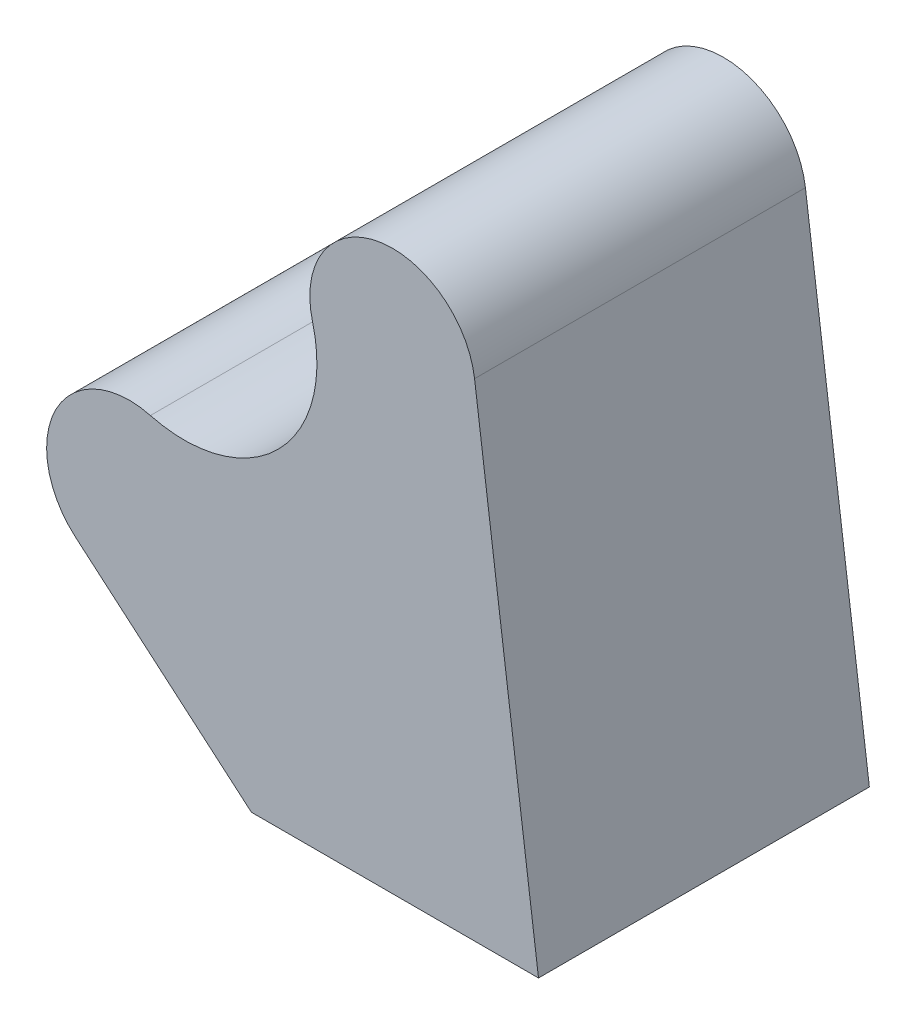
from build123d import *

# Parameters (mm, degrees)
EXTRUDE_1_DEPTH = 40


with BuildPart() as part:
    # 草图1 → 凸台-拉伸1 (new body)
    with BuildSketch(Plane.XY):
        with BuildLine():
            Line((14.754187877, -25.761886963), (49.46472486, -25.761886963))
            Line((49.46472486, -25.761886963), (41.734735589, 33.121402044))
            ThreePointArc((41.734735589, 33.121402044), (29.892363505, 41.632295596), (22.149218146, 29.274270447))
            ThreePointArc((22.149218146, 29.274270447), (17.977669058, 13.842136095), (2.545534706, 9.670587007))
            ThreePointArc((2.545534706, 9.670587007), (-8.859514659, 4.637779642), (-6.496497197, -7.602336757))
            Line((-6.496497197, -7.602336757), (14.754187877, -25.761886963))
        make_face()
    extrude(amount=EXTRUDE_1_DEPTH)


solid = part.part
